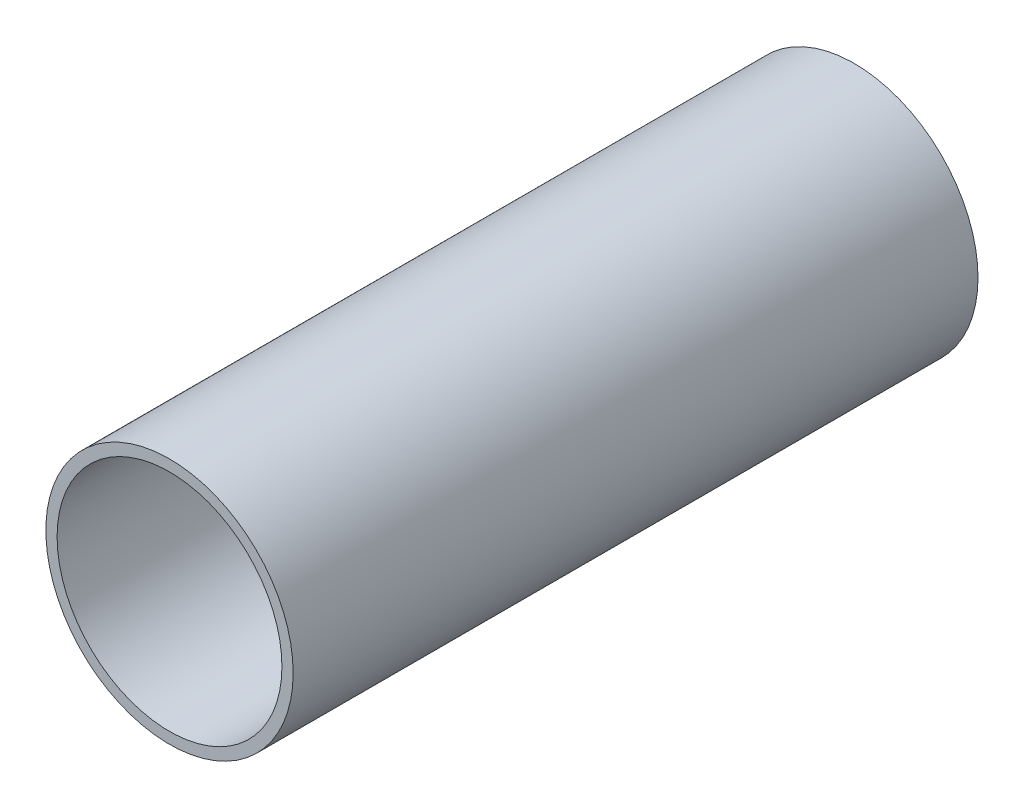
from build123d import *

# Parameters (mm, degrees)
SKETCH1_W = 457.2
SKETCH1_H = 82.55
SHELL4_T  = -7.5


with BuildPart() as part:
    # Sketch1 → Revolve1 (revolve)
    with BuildSketch(Plane(origin=(0, 0, 0), x_dir=(0, 0, -1), z_dir=(1, 0, 0)), mode=Mode.PRIVATE) as revolve1_sk:
        with Locations((0, 41.275)):
            Rectangle(SKETCH1_W, SKETCH1_H)
    revolve(revolve1_sk.sketch.rotate(Axis((0, 0, 228.6), (0, 0, -1)), 90), axis=Axis((0, 0, 228.6), (0, 0, -1)))

    # Shell4
    shell4_openings = [part.faces().sort_by_distance(p)[0] for p in [
        (0, 0, -228.6),
        (0, 0, 228.6),
    ]]
    offset(amount=SHELL4_T, openings=shell4_openings, kind=Kind.INTERSECTION)


solid = part.part
